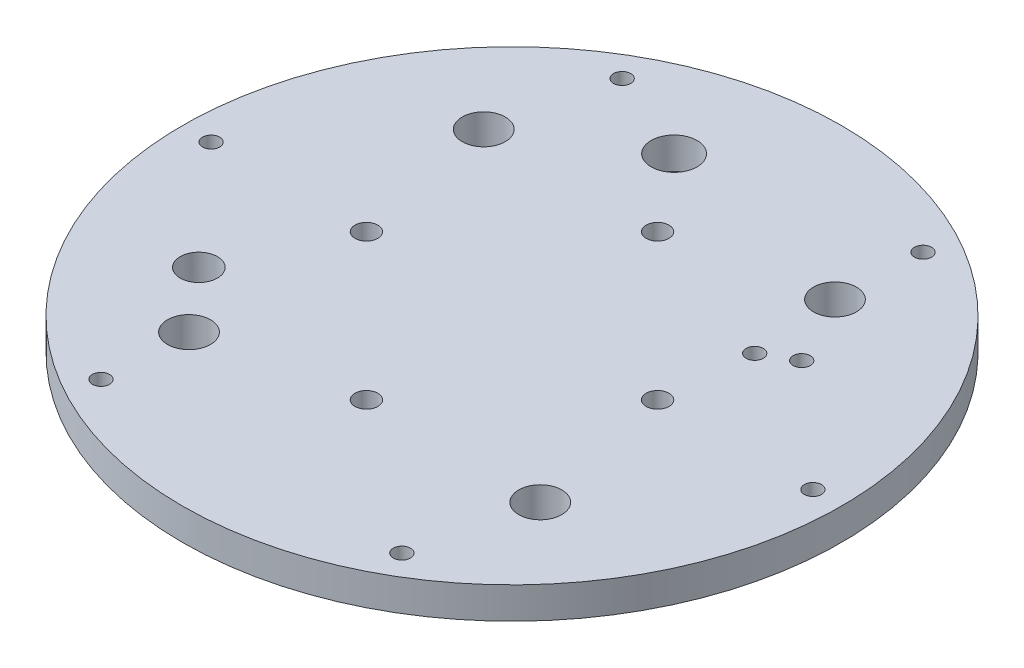
from build123d import *

# Parameters (mm, degrees)
SKETCH1_R           = 57.5
SKETCH1_R_2         = 1.5
BOSS_EXTRUDE1_DEPTH = 5.5
SKETCH3_R           = 2
CUT_EXTRUDE1_DEPTH  = 5.5
SKETCH4_R           = 3.75
CUT_EXTRUDE3_DEPTH  = 5.5
SKETCH5_R           = 3.25
CUT_EXTRUDE4_DEPTH  = 10
SKETCH6_R           = 4
SKETCH6_R_2         = 1.5
CUT_EXTRUDE5_DEPTH  = 10


with BuildPart() as part:
    # Sketch1 → Boss-Extrude1 (new body)
    with BuildSketch(Plane(origin=(0, 0, 0), x_dir=(1, 0, 0), z_dir=(0, 1, 0))):
        Circle(SKETCH1_R)
        with Locations((-52.5, 0)):
            Circle(SKETCH1_R_2, mode=Mode.SUBTRACT)
        with Locations((-26.25, 45.466333699)):
            Circle(SKETCH1_R_2, mode=Mode.SUBTRACT)
        with Locations((26.25, 45.466333699)):
            Circle(SKETCH1_R_2, mode=Mode.SUBTRACT)
        with Locations((52.5, 0)):
            Circle(SKETCH1_R_2, mode=Mode.SUBTRACT)
        with Locations((26.25, -45.466333699)):
            Circle(SKETCH1_R_2, mode=Mode.SUBTRACT)
        with Locations((-26.25, -45.466333699)):
            Circle(SKETCH1_R_2, mode=Mode.SUBTRACT)
    extrude(amount=BOSS_EXTRUDE1_DEPTH)

    # Sketch3 → Cut-Extrude1 (cut)
    with BuildSketch(Plane(origin=(0, 5.5, 0), x_dir=(1, 0, 0), z_dir=(0, 1, 0))):
        with Locations((0, 25.4)):
            Circle(SKETCH3_R)
        with Locations((25.4, 0)):
            Circle(SKETCH3_R)
        with Locations((0, -25.4)):
            Circle(SKETCH3_R)
        with Locations((-25.4, 0)):
            Circle(SKETCH3_R)
    extrude(amount=-CUT_EXTRUDE1_DEPTH, mode=Mode.SUBTRACT)

    # Sketch4 → Cut-Extrude3 (cut)
    with BuildSketch(Plane(origin=(0, 5.5, 0), x_dir=(1, 0, 0), z_dir=(0, 1, 0))):
        with Locations((-30.641777725, 25.711504387)):
            Circle(SKETCH4_R)
        with Locations((25.711504387, 30.641777725)):
            Circle(SKETCH4_R)
        with Locations((30.641777725, -25.711504387)):
            Circle(SKETCH4_R)
        with Locations((-25.711504387, -30.641777725)):
            Circle(SKETCH4_R)
    extrude(amount=-CUT_EXTRUDE3_DEPTH, mode=Mode.SUBTRACT)

    # Sketch5 → Cut-Extrude4 (cut)
    with BuildSketch(Plane.XZ):
        with Locations((-34.641016151, 20)):
            Circle(SKETCH5_R)
    extrude(amount=-CUT_EXTRUDE4_DEPTH, mode=Mode.SUBTRACT)

    # Sketch6 → Cut-Extrude5 (cut)
    with BuildSketch(Plane.XZ):
        with Locations((-10.352761804, -38.637033052)):
            Circle(SKETCH6_R)
        with Locations((32.04293994, -18.5)):
            Circle(SKETCH6_R_2)
        with Locations((26.846787517, -15.5)):
            Circle(SKETCH6_R_2)
    extrude(amount=-CUT_EXTRUDE5_DEPTH, mode=Mode.SUBTRACT)


solid = part.part
